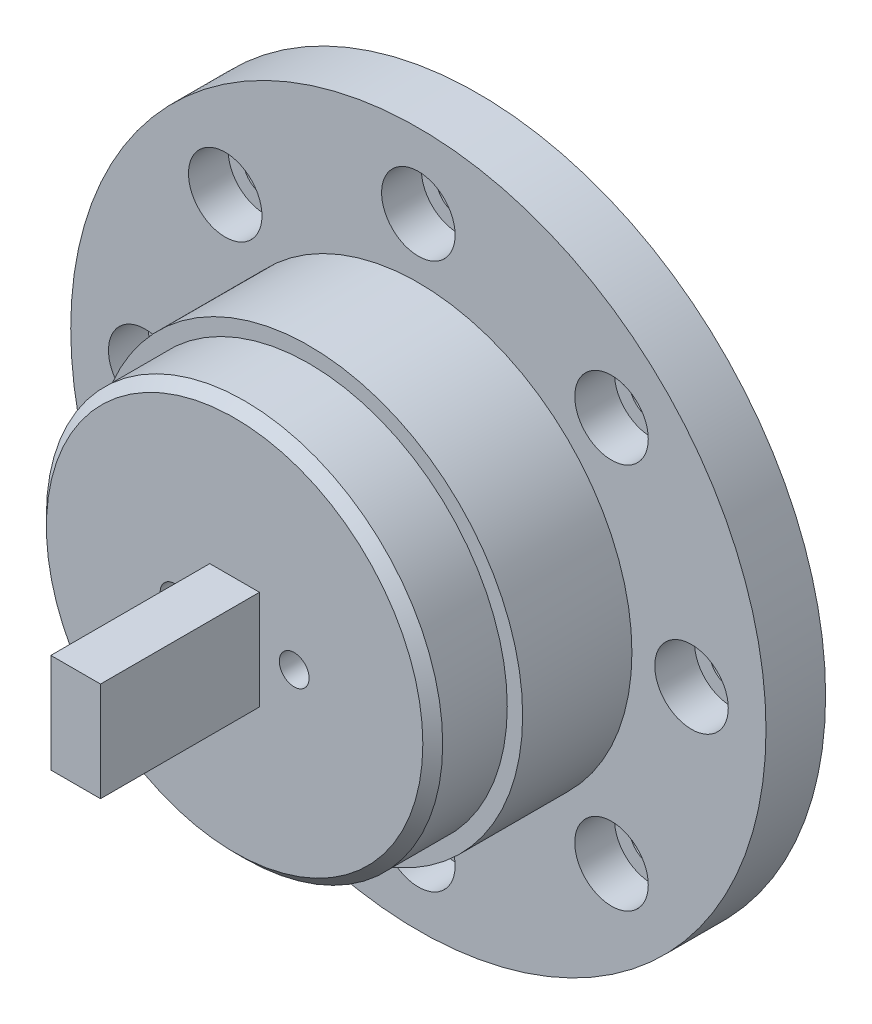
from build123d import *

# Parameters (mm, degrees)
SKETCH1_R           = 35
SKETCH1_R_2         = 2.2
BOSS_EXTRUDE1_DEPTH = 2
SKETCH2_R           = 35
SKETCH2_R_2         = 3.7
BOSS_EXTRUDE2_DEPTH = 4
SKETCH4_R           = 19.95
BOSS_EXTRUDE3_DEPTH = 18.5
SKETCH6_W           = 5
SKETCH6_H           = 10
BOSS_EXTRUDE4_DEPTH = 16
SKETCH7_R           = 21.5
BOSS_EXTRUDE5_DEPTH = 11
SKETCH5_R           = 1.5
CUT_EXTRUDE1_DEPTH  = 25.5
CHAMFER1_SIZE       = 1


with BuildPart() as part:
    # Sketch1 → Boss-Extrude1 (new body)
    with BuildSketch(Plane.XY):
        Circle(SKETCH1_R)
        with Locations((0, 27.5)):
            Circle(SKETCH1_R_2, mode=Mode.SUBTRACT)
        with Locations((19.445436483, 19.445436483)):
            Circle(SKETCH1_R_2, mode=Mode.SUBTRACT)
        with Locations((27.5, 0)):
            Circle(SKETCH1_R_2, mode=Mode.SUBTRACT)
        with Locations((19.445436483, -19.445436483)):
            Circle(SKETCH1_R_2, mode=Mode.SUBTRACT)
        with Locations((0, -27.5)):
            Circle(SKETCH1_R_2, mode=Mode.SUBTRACT)
        with Locations((-19.445436483, -19.445436483)):
            Circle(SKETCH1_R_2, mode=Mode.SUBTRACT)
        with Locations((-27.5, 0)):
            Circle(SKETCH1_R_2, mode=Mode.SUBTRACT)
        with Locations((-19.445436483, 19.445436483)):
            Circle(SKETCH1_R_2, mode=Mode.SUBTRACT)
    extrude(amount=BOSS_EXTRUDE1_DEPTH)

    # Sketch2 → Boss-Extrude2 (add)
    with BuildSketch(Plane.XY.offset(2)):
        Circle(SKETCH2_R)
        with Locations((-27.5, 0)):
            Circle(SKETCH2_R_2, mode=Mode.SUBTRACT)
        with Locations((0, -27.5)):
            Circle(SKETCH2_R_2, mode=Mode.SUBTRACT)
        with Locations((27.5, 0)):
            Circle(SKETCH2_R_2, mode=Mode.SUBTRACT)
        with Locations((0, 27.5)):
            Circle(SKETCH2_R_2, mode=Mode.SUBTRACT)
        with Locations((19.445436483, 19.445436483)):
            Circle(SKETCH2_R_2, mode=Mode.SUBTRACT)
        with Locations((19.445436483, -19.445436483)):
            Circle(SKETCH2_R_2, mode=Mode.SUBTRACT)
        with Locations((-19.445436483, -19.445436483)):
            Circle(SKETCH2_R_2, mode=Mode.SUBTRACT)
        with Locations((-19.445436483, 19.445436483)):
            Circle(SKETCH2_R_2, mode=Mode.SUBTRACT)
    extrude(amount=BOSS_EXTRUDE2_DEPTH)

    # Sketch4 → Boss-Extrude3 (add)
    with BuildSketch(Plane.XY.offset(6)):
        Circle(SKETCH4_R)
    extrude(amount=BOSS_EXTRUDE3_DEPTH)

    # Sketch6 → Boss-Extrude4 (add)
    with BuildSketch(Plane.XY.offset(24.5)):
        Rectangle(SKETCH6_W, SKETCH6_H)
    extrude(amount=BOSS_EXTRUDE4_DEPTH)

    # Sketch7 → Boss-Extrude5 (add)
    with BuildSketch(Plane.XY.offset(6)):
        Circle(SKETCH7_R)
    extrude(amount=BOSS_EXTRUDE5_DEPTH)

    # Sketch5 → Cut-Extrude1 (cut, through all)
    with BuildSketch(Plane.XY.offset(24.5)):
        with Locations((-6, 0)):
            Circle(SKETCH5_R)
        with Locations((6, 0)):
            Circle(SKETCH5_R)
    extrude(amount=-CUT_EXTRUDE1_DEPTH, mode=Mode.SUBTRACT)

    # Chamfer1
    chamfer1_edges = [part.edges().sort_by_distance(p)[0] for p in [
        (-19.95, 0, 24.5),
    ]]
    chamfer(chamfer1_edges, length=CHAMFER1_SIZE)


solid = part.part
